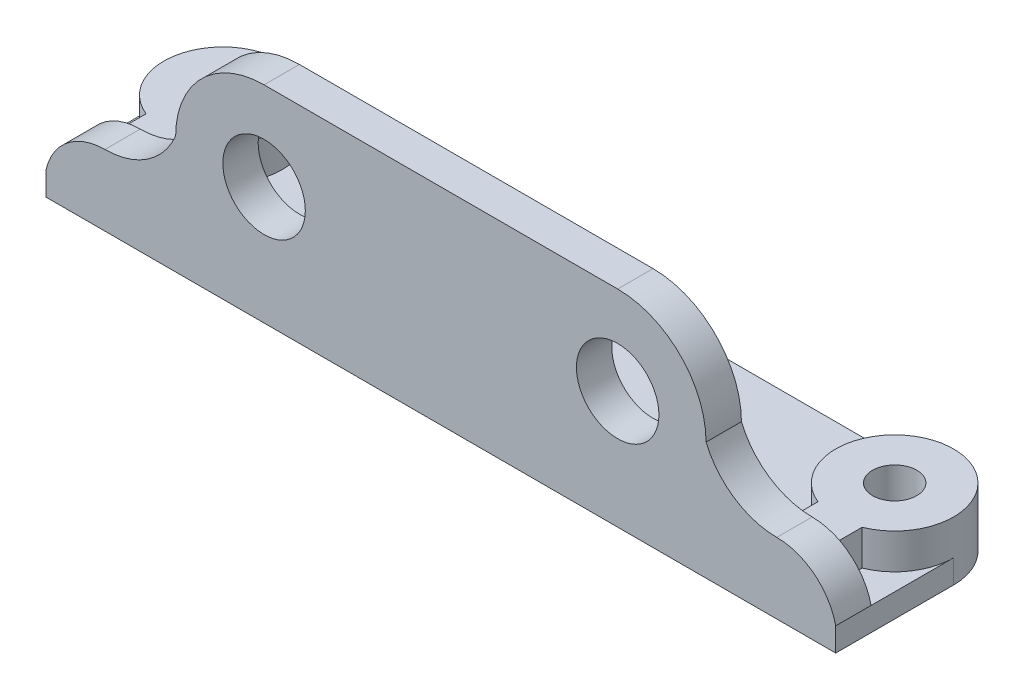
from build123d import *

# Parameters (mm, degrees)
SKETCH1_R           = 1.875
BOSS_EXTRUDE1_DEPTH = 2
SKETCH2_W           = 3.125
SKETCH2_H           = 3
SKETCH2_W_2         = 3.75
SKETCH2_W_3         = 26.625
BOSS_EXTRUDE2_DEPTH = 3
SKETCH3_W           = 67
SKETCH3_H           = 3
BOSS_EXTRUDE3_DEPTH = 20
CUT_EXTRUDE1_REACH  = 70.513
SKETCH4_R           = 3.5


with BuildPart() as part:
    # Sketch1 → Boss-Extrude1 (new body)
    with BuildSketch(Plane(origin=(0, 0, 0), x_dir=(1, 0, 0), z_dir=(0, 1, 0))):
        with BuildLine():
            Line((0, 5), (57, 5))
            ThreePointArc((57, 5), (60.535533906, 3.535533906), (62, 0))
            Line((62, 0), (62, -10))
            Line((62, -10), (-5, -10))
            Line((-5, -10), (-5, 0))
            ThreePointArc((-5, 0), (-3.535533906, 3.535533906), (0, 5))
        make_face()
        with Locations(Location((0, 0, 0), (0, 0, 270))):
            Circle(SKETCH1_R, mode=Mode.SUBTRACT)
        with Locations(Location((57, 0, 0), (0, 0, 270))):
            Circle(SKETCH1_R, mode=Mode.SUBTRACT)
    extrude(amount=BOSS_EXTRUDE1_DEPTH)

    # Sketch2 → Boss-Extrude2 (add)
    with BuildSketch(Plane(origin=(0, 2, 0), x_dir=(1, 0, 0), z_dir=(0, 1, 0))):
        with BuildLine():
            ThreePointArc((0, 5), (-3.535533906, 3.535533906), (-5, 0))
            ThreePointArc((-5, 0), (-4.145780988, -2.795084972), (-1.875, -4.635124054))
            Line((-1.875, -4.635124054), (-1.875, 0))
            ThreePointArc((-1.875, 0), (0, 1.875), (1.875, 0))
            Line((1.875, 0), (1.875, -4.635124054))
            ThreePointArc((1.875, -4.635124054), (4.145780988, -2.795084972), (5, 0))
            ThreePointArc((5, 0), (3.535533906, 3.535533906), (0, 5))
        make_face()
        with BuildLine():
            Line((-1.875, 0), (-1.875, -4.635124054))
            ThreePointArc((-1.875, -4.635124054), (0, -5), (1.875, -4.635124054))
            Line((1.875, -4.635124054), (1.875, 0))
            ThreePointArc((1.875, 0), (0, -1.875), (-1.875, 0))
        make_face()
        with BuildLine():
            Line((-1.875, -4.635124054), (-1.875, -7))
            Line((-1.875, -7), (1.875, -7))
            Line((1.875, -7), (1.875, -4.635124054))
            ThreePointArc((1.875, -4.635124054), (0, -5), (-1.875, -4.635124054))
        make_face()
        with Locations((-3.4375, -8.5)):
            Rectangle(SKETCH2_W, SKETCH2_H)
        with Locations((0, -8.5)):
            Rectangle(SKETCH2_W_2, SKETCH2_H)
        with Locations((15.1875, -8.5)):
            Rectangle(SKETCH2_W_3, SKETCH2_H)
        with BuildLine():
            ThreePointArc((57, 5), (52.092066613, 0.955086312), (55.125, -4.635124054))
            Line((55.125, -4.635124054), (55.125, 0))
            ThreePointArc((55.125, 0), (57, 1.875), (58.875, 0))
            Line((58.875, 0), (58.875, -4.635124054))
            ThreePointArc((58.875, -4.635124054), (61.145780988, -2.795084972), (62, 0))
            ThreePointArc((62, 0), (60.535533906, 3.535533906), (57, 5))
        make_face()
        with BuildLine():
            Line((55.125, 0), (55.125, -4.635124054))
            ThreePointArc((55.125, -4.635124054), (57, -5), (58.875, -4.635124054))
            Line((58.875, -4.635124054), (58.875, 0))
            ThreePointArc((58.875, 0), (57, -1.875), (55.125, 0))
        make_face()
        with BuildLine():
            Line((55.125, -4.635124054), (55.125, -7))
            Line((55.125, -7), (58.875, -7))
            Line((58.875, -7), (58.875, -4.635124054))
            ThreePointArc((58.875, -4.635124054), (57, -5), (55.125, -4.635124054))
        make_face()
        with Locations((60.4375, -8.5)):
            Rectangle(SKETCH2_W, SKETCH2_H)
        with Locations((57, -8.5)):
            Rectangle(SKETCH2_W_2, SKETCH2_H)
        with Locations((41.8125, -8.5)):
            Rectangle(SKETCH2_W_3, SKETCH2_H)
    extrude(amount=BOSS_EXTRUDE2_DEPTH)

    # Sketch3 → Boss-Extrude3 (add)
    with BuildSketch(Plane(origin=(0, 5, 0), x_dir=(1, 0, 0), z_dir=(0, 1, 0))):
        with Locations((28.5, -8.5)):
            Rectangle(SKETCH3_W, SKETCH3_H)
    extrude(amount=BOSS_EXTRUDE3_DEPTH)

    # Sketch4 → Cut-Extrude1 (cut, up to next)
    with BuildSketch(Plane.XY.offset(10), mode=Mode.PRIVATE) as cut_extrude1_sk1:
        with BuildLine():
            ThreePointArc((-5, 2), (-3.201562119, 4.876952648), (0, 6))
            ThreePointArc((0, 6), (3.605551275, 7.091673087), (6, 10))
            ThreePointArc((6, 10), (8.196699141, 15.303300859), (13.5, 17.5))
            Line((13.5, 17.5), (43.5, 17.5))
            ThreePointArc((43.5, 17.5), (48.803300859, 15.303300859), (51, 10))
            ThreePointArc((51, 10), (53.394448725, 7.091673087), (57, 6))
            ThreePointArc((57, 6), (60.201562119, 4.876952648), (62, 2))
            Line((62, 2), (62, 25))
            Line((62, 25), (-5, 25))
            Line((-5, 25), (-5, 2))
        make_face()
    cut_extrude1_tool1 = extrude(cut_extrude1_sk1.sketch, amount=-CUT_EXTRUDE1_REACH, mode=Mode.PRIVATE) & part.part
    # Sketch4 → Cut-Extrude1 (cut, up to next)
    with BuildSketch(Plane.XY.offset(10), mode=Mode.PRIVATE) as cut_extrude1_sk2:
        with Locations((13.5, 10)):
            Circle(SKETCH4_R)
    cut_extrude1_tool2 = extrude(cut_extrude1_sk2.sketch, amount=-CUT_EXTRUDE1_REACH, mode=Mode.PRIVATE) & part.part
    # Sketch4 → Cut-Extrude1 (cut, up to next)
    with BuildSketch(Plane.XY.offset(10), mode=Mode.PRIVATE) as cut_extrude1_sk3:
        with Locations((43.5, 10)):
            Circle(SKETCH4_R)
    cut_extrude1_tool3 = extrude(cut_extrude1_sk3.sketch, amount=-CUT_EXTRUDE1_REACH, mode=Mode.PRIVATE) & part.part
    add(cut_extrude1_tool1.solids().sort_by_distance((28.5, 18.015348, 10))[0], mode=Mode.SUBTRACT)
    add(cut_extrude1_tool2.solids().sort_by_distance((13.5, 10, 10))[0], mode=Mode.SUBTRACT)
    add(cut_extrude1_tool3.solids().sort_by_distance((43.5, 10, 10))[0], mode=Mode.SUBTRACT)


solid = part.part
